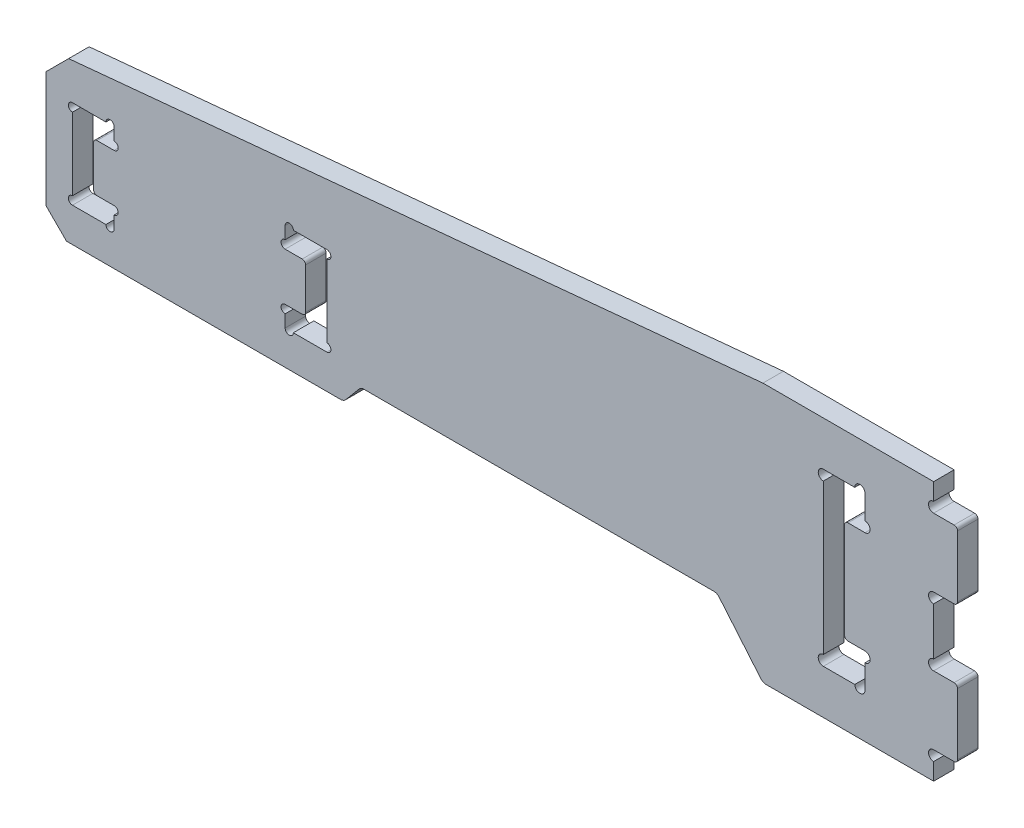
from build123d import *

# Parameters (mm, degrees)
SKETCH_1_W             = 130
SKETCH_1_H             = 38
EXTRUDE_1_DEPTH        = 1.5
SKETCH_2_W             = 3.5
SKETCH_2_H             = 10
EXTRUDE_2_DEPTH        = 3
CUT_EXTRUDE_2_DEPTH    = 4
SKETCH_3_R             = 0.75
CUT_EXTRUDE_1_DEPTH    = 4
FILLET_1_R             = 0.5
CUT_EXTRUDE_3_DEPTH    = 4
FILLET_2_R             = 1
CUT_EXTRUDE_4_DEPTH    = 4
CUT_EXTRUDE_6_DEPTH    = 4
SKETCH_9_R             = 0.6
CUT_EXTRUDE_7_DEPTH    = 4
FILLET_3_R             = 0.5
CUT_EXTRUDE_8_DEPTH    = 4
FILLET_4_R             = 1
CHAMFER_1_SIZE         = 3
CHAMFER_1_EDGE_2_SIZE2 = 3.330793123
CHAMFER_1_EDGE_2_SIZE  = 3


with BuildPart() as part:
    # 草图1 → 凸台-拉伸1 (new body, symmetric)
    with BuildSketch(Plane.XY):
        Rectangle(SKETCH_1_W, SKETCH_1_H)
    extrude(amount=EXTRUDE_1_DEPTH, both=True)

    # 草图2 → 凸台-拉伸2 (add)
    with BuildSketch(Plane.XY.offset(1.5)):
        with Locations((66.75, 10)):
            Rectangle(SKETCH_2_W, SKETCH_2_H)
        with Locations((66.75, -10)):
            Rectangle(SKETCH_2_W, SKETCH_2_H)
    extrude(amount=-EXTRUDE_2_DEPTH)

    # 草图4 → 切除-拉伸2 (cut, through all)
    with BuildSketch(Plane.XY.offset(1.5)):
        Polygon((48.85, 12.5), (54.95, 12.5), (54.95, 7.5), (51.95, 7.5), (51.95, -7.5), (54.95, -7.5), (54.95, -12.5), (48.85, -12.5), align=None)
    extrude(amount=-CUT_EXTRUDE_2_DEPTH, mode=Mode.SUBTRACT)

    # 草图3 → 切除-拉伸1 (cut, through all)
    with BuildSketch(Plane.XY.offset(1.5)):
        with Locations((65, 15.75)):
            Circle(SKETCH_3_R)
        with Locations((65, 4.25)):
            Circle(SKETCH_3_R)
        with Locations((65, -4.25)):
            Circle(SKETCH_3_R)
        with Locations((65, -15.75)):
            Circle(SKETCH_3_R)
        with Locations((54.95, 8.25)):
            Circle(SKETCH_3_R)
        with Locations((54.2, 12.5)):
            Circle(SKETCH_3_R)
        with Locations((48.85, 11.75)):
            Circle(SKETCH_3_R)
        with Locations((48.85, -11.75)):
            Circle(SKETCH_3_R)
        with Locations((54.95, -8.25)):
            Circle(SKETCH_3_R)
        with Locations((54.2, -12.5)):
            Circle(SKETCH_3_R)
    extrude(amount=-CUT_EXTRUDE_1_DEPTH, mode=Mode.SUBTRACT)

    # 圆角1
    fillet_1_edges = [part.edges().sort_by_distance(p)[0] for p in [
        (68.5, 15, 0),
        (68.5, 5, 0),
        (68.5, -5, 0),
        (68.5, -15, 0),
        (51.95, 7.5, 0),
        (51.95, -7.5, 0),
    ]]
    fillet(fillet_1_edges, radius=FILLET_1_R)

    # 草图5 → 切除-拉伸3 (cut, through all)
    with BuildSketch(Plane.XY.offset(1.5)):
        Polygon((-65, -19), (-65, -14), (35.804501844, -14), (40, -19), align=None)
    extrude(amount=-CUT_EXTRUDE_3_DEPTH, mode=Mode.SUBTRACT)

    # 圆角2
    fillet_2_edges = [part.edges().sort_by_distance(p)[0] for p in [
        (40, -19, 0),
        (35.804501844, -14, 0),
    ]]
    fillet(fillet_2_edges, radius=FILLET_2_R)

    # 草图6 → 切除-拉伸4 (cut, through all)
    with BuildSketch(Plane.XY.offset(1.5)):
        Polygon((-65, 9), (40, 19), (-65, 19), align=None)
    extrude(amount=-CUT_EXTRUDE_4_DEPTH, mode=Mode.SUBTRACT)

    # 草图8 → 切除-拉伸6 (cut, through all)
    with BuildSketch(Plane(origin=(0, 0, -1.5), x_dir=(-1, 0, 0), z_dir=(0, 0, -1))):
        Polygon((29.975, -6), (29.975, -9), (23.875, -9), (23.875, 4), (29.975, 4), (29.975, 1), (26.975, 1), (26.975, -6), align=None)
        Polygon((58.025, 1), (58.025, -6), (55.025, -6), (55.025, -9), (61.125, -9), (61.125, 4), (55.025, 4), (55.025, 1), align=None)
    extrude(amount=-CUT_EXTRUDE_6_DEPTH, mode=Mode.SUBTRACT)

    # 草图9 → 切除-拉伸7 (cut, through all)
    with BuildSketch(Plane(origin=(0, 0, -1.5), x_dir=(-1, 0, 0), z_dir=(0, 0, -1))):
        with Locations((29.975, 1.6)):
            Circle(SKETCH_9_R)
        with Locations((29.975, -6.6)):
            Circle(SKETCH_9_R)
        with Locations((29.375, -9)):
            Circle(SKETCH_9_R)
        with Locations((29.375, 4)):
            Circle(SKETCH_9_R)
        with Locations((23.875, 3.4)):
            Circle(SKETCH_9_R)
        with Locations((23.875, -8.4)):
            Circle(SKETCH_9_R)
        with Locations((55.025, -6.6)):
            Circle(SKETCH_9_R)
        with Locations((55.625, -9)):
            Circle(SKETCH_9_R)
        with Locations((55.025, 1.6)):
            Circle(SKETCH_9_R)
        with Locations((55.625, 4)):
            Circle(SKETCH_9_R)
        with Locations((61.125, 3.4)):
            Circle(SKETCH_9_R)
        with Locations((61.125, -8.4)):
            Circle(SKETCH_9_R)
    extrude(amount=-CUT_EXTRUDE_7_DEPTH, mode=Mode.SUBTRACT)

    # 圆角3
    fillet_3_edges = [part.edges().sort_by_distance(p)[0] for p in [
        (-26.975, -6, 0),
        (-26.975, 1, 0),
        (-58.025, 1, 0),
        (-58.025, -6, 0),
    ]]
    fillet(fillet_3_edges, radius=FILLET_3_R)

    # 草图11 → 切除-拉伸8 (cut, through all)
    with BuildSketch(Plane(origin=(0, 0, -1.5), x_dir=(-1, 0, 0), z_dir=(0, 0, -1))):
        with BuildLine():
            Line((21.392298894, -14), (18.875, -11))
            Line((18.875, -11), (-33.287202951, -11))
            Line((-33.287202951, -11), (-36.104238629, -14.35721239))
            ThreePointArc((-36.104238629, -14.35721239), (-35.760812448, -14.093692213), (-35.338194186, -14))
            Line((-35.338194186, -14), (21.392298894, -14))
        make_face()
    extrude(amount=-CUT_EXTRUDE_8_DEPTH, mode=Mode.SUBTRACT)

    # 圆角4
    fillet_4_edges = [part.edges().sort_by_distance(p)[0] for p in [
        (-21.392298894, -14, 0),
        (33.287202951, -11, 0),
        (-18.875, -11, 0),
    ]]
    fillet(fillet_4_edges, radius=FILLET_4_R)

    # 倒角1
    chamfer_1_edges = [part.edges().sort_by_distance(p)[0] for p in [
        (-65, -14, 0),
    ]]
    chamfer(chamfer_1_edges, length=CHAMFER_1_SIZE)

    # 倒角1 edge 2
    chamfer_1_edge_2_edges = [part.edges().sort_by_distance(p)[0] for p in [
        (-65, 9, 0),
    ]]
    chamfer(chamfer_1_edge_2_edges, length=CHAMFER_1_EDGE_2_SIZE, length2=CHAMFER_1_EDGE_2_SIZE2)


solid = part.part
